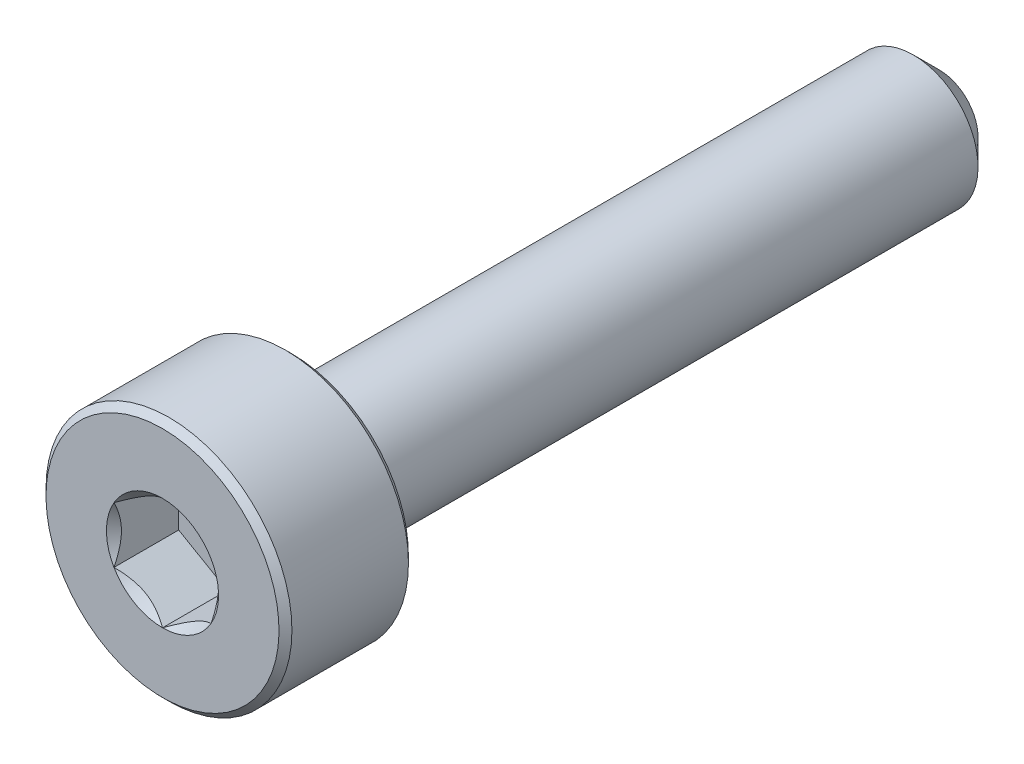
from build123d import *

# Parameters (mm, degrees)
CUT_EXTRUDE1_DEPTH = 1
SKETCH4_R          = 0.866025404
CUT_EXTRUDE2_DEPTH = 1
CUT_EXTRUDE2_DRAFT = -45


with BuildPart() as part:
    # Sketch2 → Revolve1 (revolve)
    with BuildSketch(Plane(origin=(0, 0, 0), x_dir=(0, 0, -1), z_dir=(1, 0, 0))):
        Polygon((-6, 0), (-6, 1.8), (-5.9, 1.9), (-4.1, 1.9), (-4, 1.8), (-4, 1), (5.6, 1), (6, 0.6), (6, 0), align=None)
    revolve(axis=Axis((0, 0, -6), (0, 0, 1)))

    # Sketch3 → Cut-Extrude1 (cut)
    with BuildSketch(Plane.XY.offset(6)):
        Polygon((0.75, -0.433012702), (0.75, 0.433012702), (0, 0.866025404), (-0.75, 0.433012702), (-0.75, -0.433012702), (0, -0.866025404), align=None)
    extrude(amount=-CUT_EXTRUDE1_DEPTH, mode=Mode.SUBTRACT)


with BuildPart() as cut_extrude2_tool:
    # Sketch4 → Cut-Extrude2 (with draft: the straight prism first)
    with BuildSketch(Plane.XY.offset(6)):
        Circle(SKETCH4_R)
    extrude(amount=-CUT_EXTRUDE2_DEPTH)
    # Cut-Extrude2: the draft: its side faces are tilted about the plane it starts from
    cut_extrude2_sides = [cut_extrude2_tool.faces().sort_by_distance(p)[0] for p in [
        (-0.866025404, 0, 5.5),
    ]]
    draft(cut_extrude2_sides, Plane.XY.offset(6), CUT_EXTRUDE2_DRAFT)


with BuildPart() as part_1:
    add(part.part)

    # Cut-Extrude2: cut by cut_extrude2_tool
    add(cut_extrude2_tool.part, mode=Mode.SUBTRACT)


solid = part_1.part
